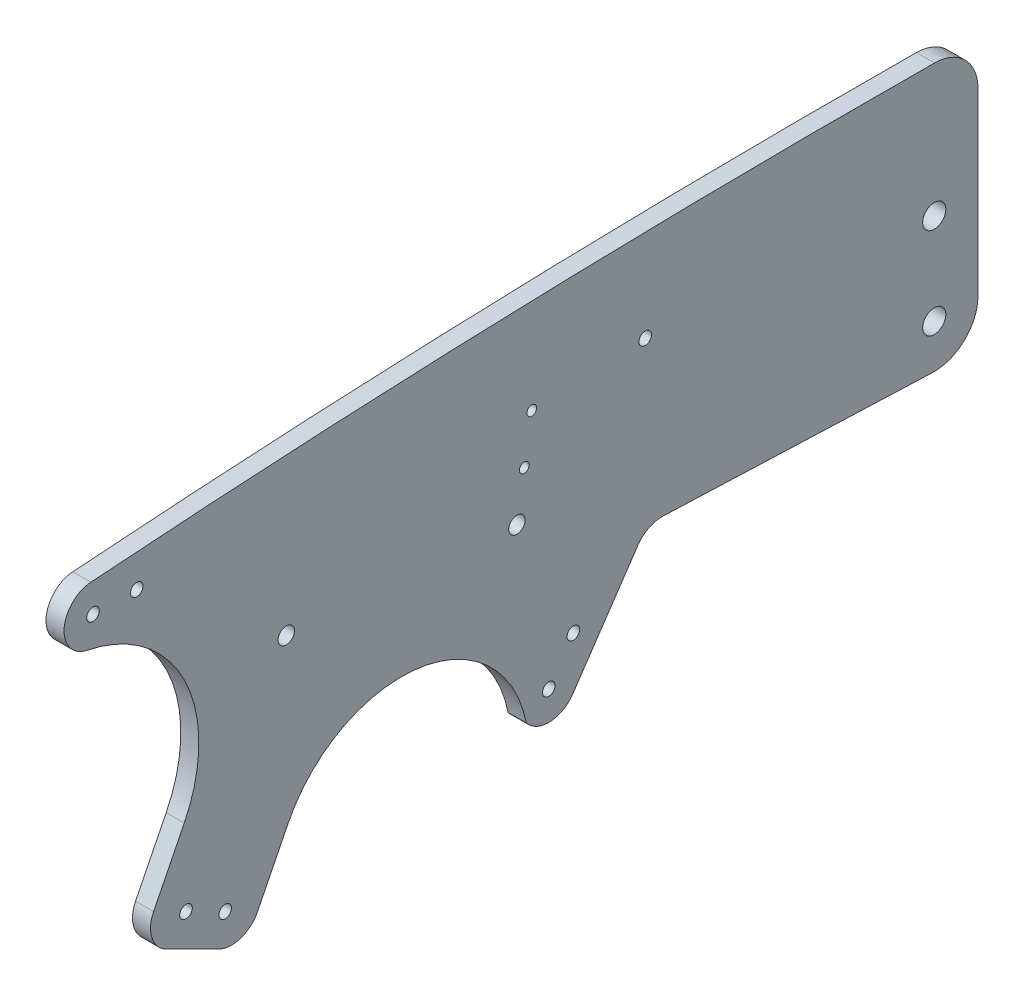
from build123d import *

# Parameters (mm, degrees)
SKETCH2_R           = 1.7272
SKETCH2_R_2         = 2.25425
SKETCH2_R_3         = 1.352550022
SKETCH2_R_4         = 3.175
BOSS_EXTRUDE1_DEPTH = 4.953


with BuildPart() as part:
    # Sketch2 → Boss-Extrude1 (new body)
    with BuildSketch(Plane(origin=(0, 0, 0), x_dir=(0, 0, -1), z_dir=(1, 0, 0))):
        with BuildLine():
            Line((-268, 33.638045694), (-268, -15.648345659))
            ThreePointArc((-268, -15.648345659), (-271.681104191, -24.296812143), (-280.46599542, -27.639294256))
            Line((-280.46599542, -27.639294256), (-354.369890721, -24.767221505))
            ThreePointArc((-354.369890721, -24.767221505), (-358.291047411, -25.622255962), (-361.303569715, -28.273908856))
            Line((-361.303569715, -28.273908856), (-379.165898581, -54.637880239))
            ThreePointArc((-379.165898581, -54.637880239), (-385.420991101, -58.116858889), (-391.93317504, -55.146852962))
            ThreePointArc((-391.93317504, -55.146852962), (-421.403553341, -27.354673474), (-457.218589828, -46.280623895))
            Line((-457.218589828, -46.280623895), (-465.626255558, -63.10041384))
            ThreePointArc((-465.626255558, -63.10041384), (-470.251425545, -67.112661913), (-476.359002427, -66.679260672))
            Line((-476.359002427, -66.679260672), (-490.566300389, -59.577494681))
            ThreePointArc((-490.566300389, -59.577494681), (-494.578548462, -54.952324694), (-494.145147221, -48.844747812))
            Line((-494.145147221, -48.844747812), (-485.73748149, -32.024957868))
            ThreePointArc((-485.73748149, -32.024957868), (-485.593767218, 1.721364638), (-512.325819935, 22.318264742))
            ThreePointArc((-512.325819935, 22.318264742), (-518.692977578, 30.592013537), (-511.35460422, 38.017906886))
            ThreePointArc((-511.35460422, 38.017906886), (-395.707987807, 44.184774715), (-279.906177735, 45.637678913))
            ThreePointArc((-279.906177735, 45.637678913), (-271.481612031, 42.090090796), (-268, 33.638045694))
        make_face()
        with Locations((-379.006254083, -40.251135649)):
            Circle(SKETCH2_R, mode=Mode.SUBTRACT)
        with Locations((-510.7706223, 30.101918548)):
            Circle(SKETCH2_R, mode=Mode.SUBTRACT)
        with Locations((-457.75455229, -1.41718755)):
            Circle(SKETCH2_R_2, mode=Mode.SUBTRACT)
        with Locations((-394.480328138, -6.767192974)):
            Circle(SKETCH2_R_2, mode=Mode.SUBTRACT)
        with Locations((-359.276554144, 19.928216477)):
            Circle(SKETCH2_R, mode=Mode.SUBTRACT)
        with Locations((-385.737171654, -50.185658721)):
            Circle(SKETCH2_R, mode=Mode.SUBTRACT)
        with Locations((-390.419716853, 18.306128226)):
            Circle(SKETCH2_R_3, mode=Mode.SUBTRACT)
        with Locations((-392.450022496, 5.769467626)):
            Circle(SKETCH2_R_3, mode=Mode.SUBTRACT)
        with Locations((-498.771367049, 29.968227033)):
            Circle(SKETCH2_R, mode=Mode.SUBTRACT)
        with Locations((-474.518853752, -58.65529334)):
            Circle(SKETCH2_R, mode=Mode.SUBTRACT)
        with Locations((-485.252549027, -53.289868312)):
            Circle(SKETCH2_R, mode=Mode.SUBTRACT)
        with Locations((-280, -15.648345659)):
            Circle(SKETCH2_R_4, mode=Mode.SUBTRACT)
        with Locations((-280, 9.351654341)):
            Circle(SKETCH2_R_4, mode=Mode.SUBTRACT)
    extrude(amount=BOSS_EXTRUDE1_DEPTH)


solid = part.part
